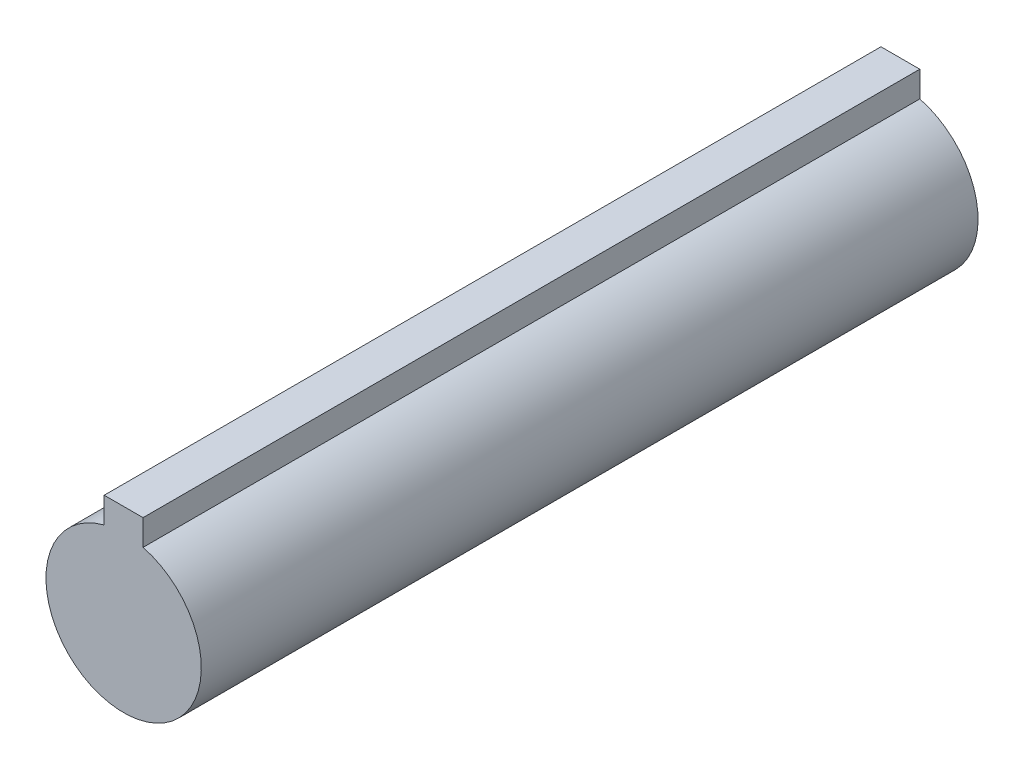
from build123d import *

# Parameters (mm, degrees)
BOSS_EXTRUDE1_DEPTH = 50


with BuildPart() as part:
    # Sketch1 → Boss-Extrude1 (new body, symmetric)
    with BuildSketch(Plane.XY):
        with BuildLine():
            Line((2.5, 9.682458366), (2.5, 13))
            Line((2.5, 13), (-2.5, 13))
            Line((-2.5, 13), (-2.5, 9.682458366))
            ThreePointArc((-2.5, 9.682458366), (0, -10), (2.5, 9.682458366))
        make_face()
    extrude(amount=BOSS_EXTRUDE1_DEPTH, both=True)


solid = part.part
